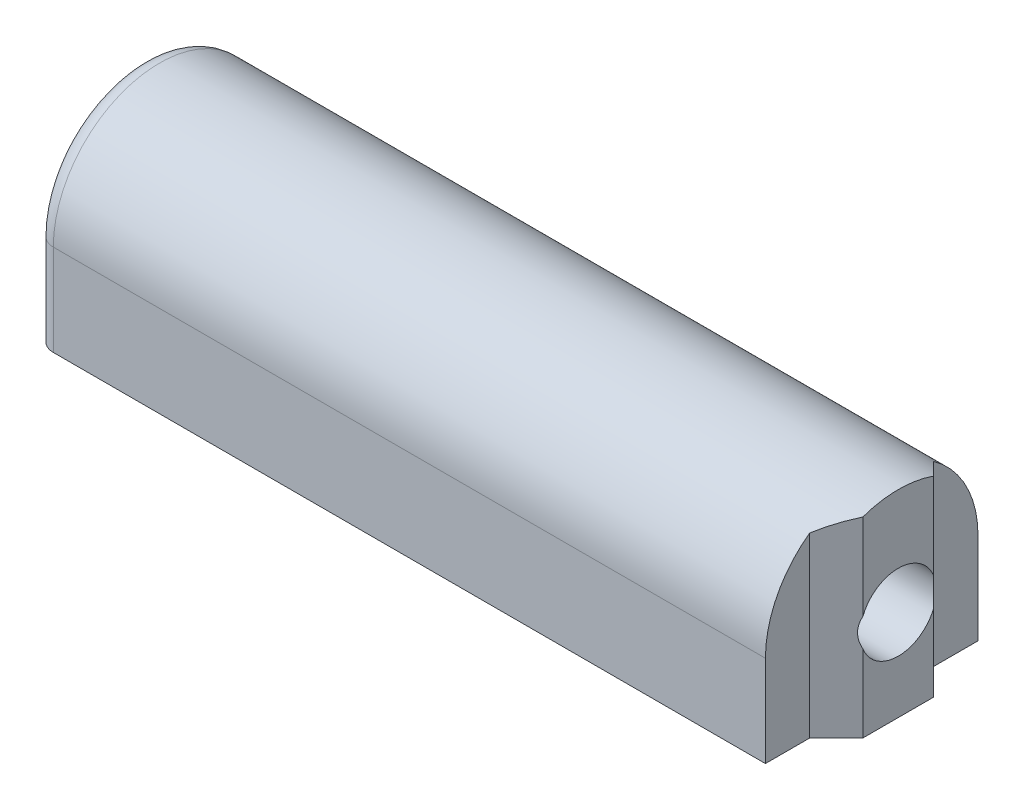
from build123d import *

# Parameters (mm, degrees)
SKETCH1_W           = 41.2
SKETCH1_H           = 13
BOSS_EXTRUDE1_DEPTH = 12
BOSS_EXTRUDE3_DEPTH = 13
SKETCH2_R           = 2.15
CUT_EXTRUDE1_DEPTH  = 43.7
FILLET1_R           = 1


with BuildPart() as part:
    # Sketch1 → Boss-Extrude1 (new body)
    with BuildSketch(Plane.XY):
        with Locations((20.6, 6.5)):
            Rectangle(SKETCH1_W, SKETCH1_H)
    extrude(amount=BOSS_EXTRUDE1_DEPTH)

    # Sketch3 → Boss-Extrude3 (add)
    with BuildSketch(Plane(origin=(0, 13, 0), x_dir=(1, 0, 0), z_dir=(0, 1, 0))):
        Polygon((42.7, -8), (41.2, -9.5), (41.2, -2.5), (42.7, -4), align=None)
    extrude(amount=-BOSS_EXTRUDE3_DEPTH)

    # Sketch2 → Cut-Extrude1 (cut, through all)
    with BuildSketch(Plane.ZY):
        with Locations((6, 5.15)):
            Circle(SKETCH2_R)
        with BuildLine():
            Line((-1.89805103, 5.15), (0, 5.15))
            ThreePointArc((0, 5.15), (6, 11.15), (12, 5.15))
            Line((12, 5.15), (16.198164726, 5.15))
            Line((16.198164726, 5.15), (16.198164726, 14.318930959))
            Line((16.198164726, 14.318930959), (-1.89805103, 14.318930959))
            Line((-1.89805103, 14.318930959), (-1.89805103, 5.15))
        make_face()
    extrude(amount=-CUT_EXTRUDE1_DEPTH, mode=Mode.SUBTRACT)

    # Fillet1
    fillet1_edges = [part.edges().sort_by_distance(p)[0] for p in [
        (0, 2.575, 0),
        (0, 2.575, 12),
        (0, 11.15, 6),
    ]]
    fillet(fillet1_edges, radius=FILLET1_R)


solid = part.part
